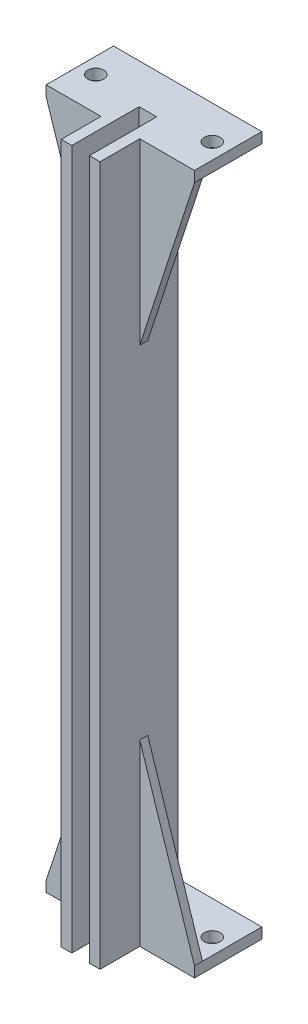
from build123d import *

# Parameters (mm, degrees)
SKETCH1_R           = 1.5
BOSS_EXTRUDE1_DEPTH = 2
BOSS_EXTRUDE2_DEPTH = 38.1
BOSS_EXTRUDE3_DEPTH = 1.5
BOSS_EXTRUDE6_DEPTH = 27.94


with BuildPart() as part:
    # Sketch1 → Boss-Extrude1 (new body)
    with BuildSketch(Plane(origin=(0, 0, 0), x_dir=(1, 0, 0), z_dir=(0, 1, 0))):
        Polygon((-14, 5.5039982), (-14, -7.1960018), (-3.6637, -7.1960018), (-3.6637, -14.7), (-1.6637, -14.7), (-1.6637, -2), (1.6637, -2), (1.6637, -14.7), (3.6637, -14.7), (3.6637, -7.1960018), (14, -7.1960018), (14, 5.5039982), align=None)
        with Locations((-11, -0.8460018)):
            Circle(SKETCH1_R, mode=Mode.SUBTRACT)
        with Locations((11, -0.8460018)):
            Circle(SKETCH1_R, mode=Mode.SUBTRACT)
    extrude(amount=BOSS_EXTRUDE1_DEPTH)

    # Sketch1_3 → Boss-Extrude2 (add)
    with BuildSketch(Plane(origin=(0, 0, 0), x_dir=(1, 0, 0), z_dir=(0, 1, 0))):
        Polygon((3.6637, 0), (-3.6637, 0), (-3.6637, -14.7), (-1.6637, -14.7), (-1.6637, -2), (1.6637, -2), (1.6637, -14.7), (3.6637, -14.7), align=None)
    extrude(amount=BOSS_EXTRUDE2_DEPTH)

    # Sketch2 → Boss-Extrude3 (add)
    with BuildSketch(Plane(origin=(0, 0, 7.1960018), x_dir=(-1, 0, 0), z_dir=(0, 0, -1))):
        Polygon((3.6637, 2), (3.6637, 33.75), (14, 2), align=None)
        Polygon((-14, 2), (-3.6637, 2), (-3.6637, 33.75), align=None)
    extrude(amount=BOSS_EXTRUDE3_DEPTH)

    # Sketch6 → Boss-Extrude6 (add)
    with BuildSketch(Plane(origin=(0, 38.1, 0), x_dir=(1, 0, 0), z_dir=(0, 1, 0))):
        Polygon((1.6637, -14.7), (3.6637, -14.7), (3.6637, 0), (-3.6637, 0), (-3.6637, -14.7), (-1.6637, -14.7), (-1.6637, -2), (1.6637, -2), align=None)
    extrude(amount=BOSS_EXTRUDE6_DEPTH)

    # Mirror6: part across plane


with BuildPart() as part_1:
    add(part.part)
    add(part.part.mirror(Plane(origin=(0, 66.04, 0), x_dir=(0, 0, 1), z_dir=(0, -1, 0))))


solid = part_1.part
